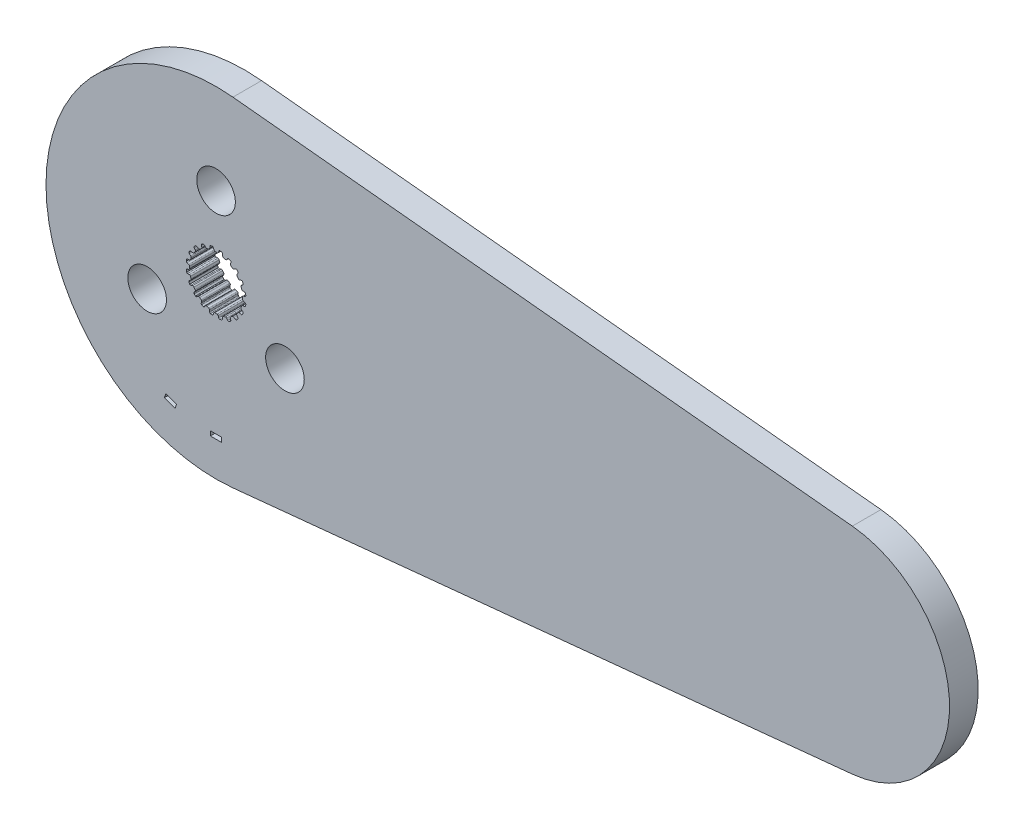
from build123d import *

# Parameters (mm, degrees)
BOSS_EXTRUDE1_DEPTH = 3.2004
SKETCH2_W           = 1.27
SKETCH2_H           = 0.508
CUT_EXTRUDE1_DEPTH  = 3.2004
SKETCH3_R           = 2.159
CUT_EXTRUDE2_DEPTH  = 3.2004


with BuildPart() as part:
    # Sketch1 → Boss-Extrude1 (new body)
    with BuildSketch(Plane.XY):
        with BuildLine():
            Line((1.886612823, 18.90776), (71.101612823, 12.0015))
            ThreePointArc((71.101612823, 12.0015), (81.965200927, 0), (71.101612823, -12.0015))
            Line((71.101612823, -12.0015), (1.886612823, -18.90776))
            ThreePointArc((1.886612823, -18.90776), (-19.001649827, 0), (1.886612823, 18.90776))
        make_face()
        with BuildLine():
            Line((-0.106949245, 2.969874934), (0.106949245, 2.969874934))
            ThreePointArc((0.106949245, 2.969874934), (0.196343213, 2.986924176), (0.253739238, 3.057547504))
            Line((0.253739238, 3.057547504), (0.315888147, 3.237526941))
            ThreePointArc((0.315888147, 3.237526941), (0.359032156, 3.298322911), (0.4281449, 3.326269005))
            Line((0.4281449, 3.326269005), (0.620027588, 3.2937547))
            ThreePointArc((0.620027588, 3.2937547), (0.689621142, 3.24802576), (0.718272212, 3.169836791))
            Line((0.718272212, 3.169836791), (0.724389167, 2.979527391))
            ThreePointArc((0.724389167, 2.979527391), (0.750934762, 2.9040661), (0.816027049, 2.857568043))
            Line((0.816027049, 2.857568043), (1.019456602, 2.791469774))
            ThreePointArc((1.019456602, 2.791469774), (1.109743823, 2.780060312), (1.186154496, 2.829490741))
            Line((1.186154496, 2.829490741), (1.300878326, 2.981456288))
            ThreePointArc((1.300878326, 2.981456288), (1.360697704, 3.02594446), (1.435063648, 3.031165762))
            Line((1.435063648, 3.031165762), (1.607507455, 2.940947809))
            ThreePointArc((1.607507455, 2.940947809), (1.659563839, 2.875951412), (1.662650905, 2.792735615))
            Line((1.662650905, 2.792735615), (1.609659636, 2.609850378))
            ThreePointArc((1.609659636, 2.609850378), (1.611587176, 2.529879385), (1.659124931, 2.465542482))
            Line((1.659124931, 2.465542482), (1.832172444, 2.339816104))
            ThreePointArc((1.832172444, 2.339816104), (1.914514976, 2.301064775), (2.002460687, 2.32446371))
            Line((2.002460687, 2.32446371), (2.158529469, 2.433539921))
            ThreePointArc((2.158529469, 2.433539921), (2.229168681, 2.457365482), (2.301508367, 2.439350895))
            Line((2.301508367, 2.439350895), (2.437633293, 2.300260456))
            ThreePointArc((2.437633293, 2.300260456), (2.467056864, 2.222358901), (2.444277744, 2.14226202))
            Line((2.444277744, 2.14226202), (2.337365406, 1.984703026))
            ThreePointArc((2.337365406, 1.984703026), (2.314486209, 1.908050449), (2.339816104, 1.832172444))
            Line((2.339816104, 1.832172444), (2.465542482, 1.659124931))
            ThreePointArc((2.465542482, 1.659124931), (2.531880064, 1.596824985), (2.622752074, 1.591901975))
            Line((2.622752074, 1.591901975), (2.804888709, 1.64741171))
            ThreePointArc((2.804888709, 1.64741171), (2.879433095, 1.648242449), (2.942665411, 1.608755366))
            Line((2.942665411, 1.608755366), (3.0291466, 1.434407582))
            ThreePointArc((3.0291466, 1.434407582), (3.033057175, 1.351226417), (2.986641646, 1.282088892))
            Line((2.986641646, 1.282088892), (2.836273564, 1.165279113))
            ThreePointArc((2.836273564, 1.165279113), (2.790827206, 1.099448241), (2.791469774, 1.019456602))
            Line((2.791469774, 1.019456602), (2.857568043, 0.816027049))
            ThreePointArc((2.857568043, 0.816027049), (2.901407091, 0.736276839), (2.986310214, 0.703513784))
            Line((2.986310214, 0.703513784), (3.1766859, 0.700023363))
            ThreePointArc((3.1766859, 0.700023363), (3.247838536, 0.677777961), (3.295773863, 0.620683653))
            Line((3.295773863, 0.620683653), (3.324145932, 0.4281449))
            ThreePointArc((3.324145932, 0.4281449), (3.302160717, 0.347826477), (3.236652255, 0.29641597))
            Line((3.236652255, 0.29641597), (3.057547504, 0.231789562))
            ThreePointArc((3.057547504, 0.231789562), (2.993982591, 0.183224379), (2.969874934, 0.106949245))
            Line((2.969874934, 0.106949245), (2.969874934, -0.106949245))
            ThreePointArc((2.969874934, -0.106949245), (2.986924176, -0.196343213), (3.057547504, -0.253739238))
            Line((3.057547504, -0.253739238), (3.237526941, -0.315888147))
            ThreePointArc((3.237526941, -0.315888147), (3.298322911, -0.359032156), (3.326269005, -0.4281449))
            Line((3.326269005, -0.4281449), (3.2937547, -0.620027588))
            ThreePointArc((3.2937547, -0.620027588), (3.24802576, -0.689621142), (3.169836791, -0.718272212))
            Line((3.169836791, -0.718272212), (2.979527391, -0.724389167))
            ThreePointArc((2.979527391, -0.724389167), (2.9040661, -0.750934762), (2.857568043, -0.816027049))
            Line((2.857568043, -0.816027049), (2.791469774, -1.019456602))
            ThreePointArc((2.791469774, -1.019456602), (2.780060312, -1.109743823), (2.829490741, -1.186154496))
            Line((2.829490741, -1.186154496), (2.981456288, -1.300878326))
            ThreePointArc((2.981456288, -1.300878326), (3.02594446, -1.360697704), (3.031165762, -1.435063648))
            Line((3.031165762, -1.435063648), (2.940947809, -1.607507455))
            ThreePointArc((2.940947809, -1.607507455), (2.875951412, -1.659563839), (2.792735615, -1.662650905))
            Line((2.792735615, -1.662650905), (2.609850378, -1.609659636))
            ThreePointArc((2.609850378, -1.609659636), (2.529879385, -1.611587176), (2.465542482, -1.659124931))
            Line((2.465542482, -1.659124931), (2.339816104, -1.832172444))
            ThreePointArc((2.339816104, -1.832172444), (2.301064775, -1.914514976), (2.32446371, -2.002460687))
            Line((2.32446371, -2.002460687), (2.433539921, -2.158529469))
            ThreePointArc((2.433539921, -2.158529469), (2.457365482, -2.229168681), (2.439350895, -2.301508367))
            Line((2.439350895, -2.301508367), (2.300260456, -2.437633293))
            ThreePointArc((2.300260456, -2.437633293), (2.222358901, -2.467056864), (2.14226202, -2.444277744))
            Line((2.14226202, -2.444277744), (1.984703026, -2.337365406))
            ThreePointArc((1.984703026, -2.337365406), (1.908050449, -2.314486209), (1.832172444, -2.339816104))
            Line((1.832172444, -2.339816104), (1.659124931, -2.465542482))
            ThreePointArc((1.659124931, -2.465542482), (1.596824985, -2.531880064), (1.591901975, -2.622752074))
            Line((1.591901975, -2.622752074), (1.64741171, -2.804888709))
            ThreePointArc((1.64741171, -2.804888709), (1.648242449, -2.879433095), (1.608755366, -2.942665411))
            Line((1.608755366, -2.942665411), (1.434407582, -3.0291466))
            ThreePointArc((1.434407582, -3.0291466), (1.351226417, -3.033057175), (1.282088892, -2.986641646))
            Line((1.282088892, -2.986641646), (1.165279113, -2.836273564))
            ThreePointArc((1.165279113, -2.836273564), (1.099448241, -2.790827206), (1.019456602, -2.791469774))
            Line((1.019456602, -2.791469774), (0.816027049, -2.857568043))
            ThreePointArc((0.816027049, -2.857568043), (0.736276839, -2.901407091), (0.703513784, -2.986310214))
            Line((0.703513784, -2.986310214), (0.700023363, -3.1766859))
            ThreePointArc((0.700023363, -3.1766859), (0.677777961, -3.247838536), (0.620683653, -3.295773863))
            Line((0.620683653, -3.295773863), (0.4281449, -3.324145932))
            ThreePointArc((0.4281449, -3.324145932), (0.347826477, -3.302160717), (0.29641597, -3.236652255))
            Line((0.29641597, -3.236652255), (0.231789562, -3.057547504))
            ThreePointArc((0.231789562, -3.057547504), (0.183224379, -2.993982591), (0.106949245, -2.969874934))
            Line((0.106949245, -2.969874934), (-0.106949245, -2.969874934))
            ThreePointArc((-0.106949245, -2.969874934), (-0.196343213, -2.986924176), (-0.253739238, -3.057547504))
            Line((-0.253739238, -3.057547504), (-0.315888147, -3.237526941))
            ThreePointArc((-0.315888147, -3.237526941), (-0.359032156, -3.298322911), (-0.4281449, -3.326269005))
            Line((-0.4281449, -3.326269005), (-0.620027588, -3.2937547))
            ThreePointArc((-0.620027588, -3.2937547), (-0.689621142, -3.24802576), (-0.718272212, -3.169836791))
            Line((-0.718272212, -3.169836791), (-0.724389167, -2.979527391))
            ThreePointArc((-0.724389167, -2.979527391), (-0.750934762, -2.9040661), (-0.816027049, -2.857568043))
            Line((-0.816027049, -2.857568043), (-1.019456602, -2.791469774))
            ThreePointArc((-1.019456602, -2.791469774), (-1.109743823, -2.780060312), (-1.186154496, -2.829490741))
            Line((-1.186154496, -2.829490741), (-1.300878326, -2.981456288))
            ThreePointArc((-1.300878326, -2.981456288), (-1.360697704, -3.02594446), (-1.435063648, -3.031165762))
            Line((-1.435063648, -3.031165762), (-1.607507455, -2.940947809))
            ThreePointArc((-1.607507455, -2.940947809), (-1.659563839, -2.875951412), (-1.662650905, -2.792735615))
            Line((-1.662650905, -2.792735615), (-1.609659636, -2.609850378))
            ThreePointArc((-1.609659636, -2.609850378), (-1.611587176, -2.529879385), (-1.659124931, -2.465542482))
            Line((-1.659124931, -2.465542482), (-1.832172444, -2.339816104))
            ThreePointArc((-1.832172444, -2.339816104), (-1.914514976, -2.301064775), (-2.002460687, -2.32446371))
            Line((-2.002460687, -2.32446371), (-2.158529469, -2.433539921))
            ThreePointArc((-2.158529469, -2.433539921), (-2.229168681, -2.457365482), (-2.301508367, -2.439350895))
            Line((-2.301508367, -2.439350895), (-2.437633293, -2.300260456))
            ThreePointArc((-2.437633293, -2.300260456), (-2.467056864, -2.222358901), (-2.444277744, -2.14226202))
            Line((-2.444277744, -2.14226202), (-2.337365406, -1.984703026))
            ThreePointArc((-2.337365406, -1.984703026), (-2.314486209, -1.908050449), (-2.339816104, -1.832172444))
            Line((-2.339816104, -1.832172444), (-2.465542482, -1.659124931))
            ThreePointArc((-2.465542482, -1.659124931), (-2.531880064, -1.596824985), (-2.622752074, -1.591901975))
            Line((-2.622752074, -1.591901975), (-2.804888709, -1.64741171))
            ThreePointArc((-2.804888709, -1.64741171), (-2.879433095, -1.648242449), (-2.942665411, -1.608755366))
            Line((-2.942665411, -1.608755366), (-3.0291466, -1.434407582))
            ThreePointArc((-3.0291466, -1.434407582), (-3.033057175, -1.351226417), (-2.986641646, -1.282088892))
            Line((-2.986641646, -1.282088892), (-2.836273564, -1.165279113))
            ThreePointArc((-2.836273564, -1.165279113), (-2.790827206, -1.099448241), (-2.791469774, -1.019456602))
            Line((-2.791469774, -1.019456602), (-2.857568043, -0.816027049))
            ThreePointArc((-2.857568043, -0.816027049), (-2.901407091, -0.736276839), (-2.986310214, -0.703513784))
            Line((-2.986310214, -0.703513784), (-3.1766859, -0.700023363))
            ThreePointArc((-3.1766859, -0.700023363), (-3.247838536, -0.677777961), (-3.295773863, -0.620683653))
            Line((-3.295773863, -0.620683653), (-3.324145932, -0.4281449))
            ThreePointArc((-3.324145932, -0.4281449), (-3.302160717, -0.347826477), (-3.236652255, -0.29641597))
            Line((-3.236652255, -0.29641597), (-3.057547504, -0.231789562))
            ThreePointArc((-3.057547504, -0.231789562), (-2.993982591, -0.183224379), (-2.969874934, -0.106949245))
            Line((-2.969874934, -0.106949245), (-2.969874934, 0.106949245))
            ThreePointArc((-2.969874934, 0.106949245), (-2.986924176, 0.196343213), (-3.057547504, 0.253739238))
            Line((-3.057547504, 0.253739238), (-3.237526941, 0.315888147))
            ThreePointArc((-3.237526941, 0.315888147), (-3.298322911, 0.359032156), (-3.326269005, 0.4281449))
            Line((-3.326269005, 0.4281449), (-3.2937547, 0.620027588))
            ThreePointArc((-3.2937547, 0.620027588), (-3.24802576, 0.689621142), (-3.169836791, 0.718272212))
            Line((-3.169836791, 0.718272212), (-2.979527391, 0.724389167))
            ThreePointArc((-2.979527391, 0.724389167), (-2.9040661, 0.750934762), (-2.857568043, 0.816027049))
            Line((-2.857568043, 0.816027049), (-2.791469774, 1.019456602))
            ThreePointArc((-2.791469774, 1.019456602), (-2.780060312, 1.109743823), (-2.829490741, 1.186154496))
            Line((-2.829490741, 1.186154496), (-2.981456288, 1.300878326))
            ThreePointArc((-2.981456288, 1.300878326), (-3.02594446, 1.360697704), (-3.031165762, 1.435063648))
            Line((-3.031165762, 1.435063648), (-2.940947809, 1.607507455))
            ThreePointArc((-2.940947809, 1.607507455), (-2.875951412, 1.659563839), (-2.792735615, 1.662650905))
            Line((-2.792735615, 1.662650905), (-2.609850378, 1.609659636))
            ThreePointArc((-2.609850378, 1.609659636), (-2.529879385, 1.611587176), (-2.465542482, 1.659124931))
            Line((-2.465542482, 1.659124931), (-2.339816104, 1.832172444))
            ThreePointArc((-2.339816104, 1.832172444), (-2.301064775, 1.914514976), (-2.32446371, 2.002460687))
            Line((-2.32446371, 2.002460687), (-2.433539921, 2.158529469))
            ThreePointArc((-2.433539921, 2.158529469), (-2.457365482, 2.229168681), (-2.439350895, 2.301508367))
            Line((-2.439350895, 2.301508367), (-2.300260456, 2.437633293))
            ThreePointArc((-2.300260456, 2.437633293), (-2.222358901, 2.467056864), (-2.14226202, 2.444277744))
            Line((-2.14226202, 2.444277744), (-1.984703026, 2.337365406))
            ThreePointArc((-1.984703026, 2.337365406), (-1.908050449, 2.314486209), (-1.832172444, 2.339816104))
            Line((-1.832172444, 2.339816104), (-1.659124931, 2.465542482))
            ThreePointArc((-1.659124931, 2.465542482), (-1.596824985, 2.531880064), (-1.591901975, 2.622752074))
            Line((-1.591901975, 2.622752074), (-1.64741171, 2.804888709))
            ThreePointArc((-1.64741171, 2.804888709), (-1.648242449, 2.879433095), (-1.608755366, 2.942665411))
            Line((-1.608755366, 2.942665411), (-1.434407582, 3.0291466))
            ThreePointArc((-1.434407582, 3.0291466), (-1.351226417, 3.033057175), (-1.282088892, 2.986641646))
            Line((-1.282088892, 2.986641646), (-1.165279113, 2.836273564))
            ThreePointArc((-1.165279113, 2.836273564), (-1.099448241, 2.790827206), (-1.019456602, 2.791469774))
            Line((-1.019456602, 2.791469774), (-0.816027049, 2.857568043))
            ThreePointArc((-0.816027049, 2.857568043), (-0.736276839, 2.901407091), (-0.703513784, 2.986310214))
            Line((-0.703513784, 2.986310214), (-0.700023363, 3.1766859))
            ThreePointArc((-0.700023363, 3.1766859), (-0.677777961, 3.247838536), (-0.620683653, 3.295773863))
            Line((-0.620683653, 3.295773863), (-0.4281449, 3.324145932))
            ThreePointArc((-0.4281449, 3.324145932), (-0.347826477, 3.302160717), (-0.29641597, 3.236652255))
            Line((-0.29641597, 3.236652255), (-0.231789562, 3.057547504))
            ThreePointArc((-0.231789562, 3.057547504), (-0.183224379, 2.993982591), (-0.106949245, 2.969874934))
        make_face(mode=Mode.SUBTRACT)
    extrude(amount=BOSS_EXTRUDE1_DEPTH)

    # Sketch2 → Cut-Extrude1 (cut)
    with BuildSketch(Plane.XY.offset(3.2004)):
        Polygon((-4.582879775, -14.447974492), (-4.409133542, -13.970610641), (-5.602543171, -13.536245059), (-5.776289403, -14.01360891), align=None)
        with Locations((0, -14.890092213)):
            Rectangle(SKETCH2_W, SKETCH2_H)
    extrude(amount=-CUT_EXTRUDE1_DEPTH, mode=Mode.SUBTRACT)

    # Sketch3 → Cut-Extrude2 (cut)
    with BuildSketch(Plane.XY.offset(3.2004)):
        with Locations((0, 8.89)):
            Circle(SKETCH3_R)
        with Locations((7.69896584, -4.445)):
            Circle(SKETCH3_R)
        with Locations((-7.69896584, -4.445)):
            Circle(SKETCH3_R)
    extrude(amount=-CUT_EXTRUDE2_DEPTH, mode=Mode.SUBTRACT)


solid = part.part
